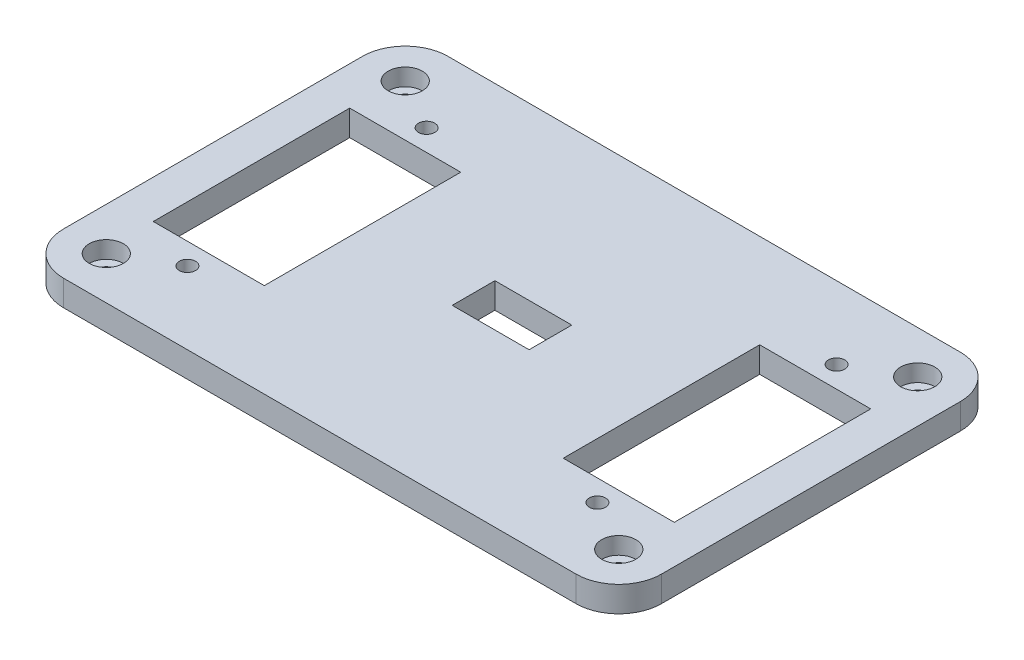
from build123d import *

# Parameters (mm, degrees)
SKETCH_1_W          = 70
SKETCH_1_H          = 45
EXTRUDE_1_DEPTH     = 3
SKETCH_2_W          = 13
SKETCH_2_H          = 23
CUT_EXTRUDE_1_DEPTH = 10
SKETCH_3_R          = 0.95
CUT_EXTRUDE_2_DEPTH = 10
FILLET_1_R          = 5
FILLET_2_R          = 5
SKETCH_4_R          = 0.95
CUT_EXTRUDE_3_DEPTH = 10
SKETCH_5_R          = 2
CUT_EXTRUDE_4_DEPTH = 2
SKETCH_6_W          = 9
SKETCH_6_H          = 5
CUT_EXTRUDE_5_DEPTH = 14


with BuildPart() as part:
    # 草图1 → 凸台-拉伸1 (new body)
    with BuildSketch(Plane(origin=(0, 0, 0), x_dir=(1, 0, 0), z_dir=(0, 1, 0))):
        Rectangle(SKETCH_1_W, SKETCH_1_H)
    extrude(amount=EXTRUDE_1_DEPTH)

    # 草图2 → 切除-拉伸1 (cut)
    with BuildSketch(Plane(origin=(0, 3, 0), x_dir=(1, 0, 0), z_dir=(0, 1, 0))):
        with Locations((24, 0)):
            Rectangle(SKETCH_2_W, SKETCH_2_H)
        with Locations((-24, 0)):
            Rectangle(SKETCH_2_W, SKETCH_2_H)
    extrude(amount=-CUT_EXTRUDE_1_DEPTH, mode=Mode.SUBTRACT)

    # 草图3 → 切除-拉伸2 (cut)
    with BuildSketch(Plane(origin=(0, 3, 0), x_dir=(1, 0, 0), z_dir=(0, 1, 0))):
        with Locations((-24, 14)):
            Circle(SKETCH_3_R)
        with Locations((-24, -14)):
            Circle(SKETCH_3_R)
        with Locations((24, 14)):
            Circle(SKETCH_3_R)
        with Locations((24, -14)):
            Circle(SKETCH_3_R)
    extrude(amount=-CUT_EXTRUDE_2_DEPTH, mode=Mode.SUBTRACT)

    # 圆角1
    fillet_1_edges = [part.edges().sort_by_distance(p)[0] for p in [
        (35, 1.5, -22.5),
    ]]
    fillet(fillet_1_edges, radius=FILLET_1_R)

    # 圆角2
    fillet_2_edges = [part.edges().sort_by_distance(p)[0] for p in [
        (35, 1.5, 22.5),
        (-35, 1.5, 22.5),
        (-35, 1.5, -22.5),
    ]]
    fillet(fillet_2_edges, radius=FILLET_2_R)

    # 草图4 → 切除-拉伸3 (cut)
    with BuildSketch(Plane(origin=(0, 3, 0), x_dir=(1, 0, 0), z_dir=(0, 1, 0))):
        with Locations((-30, 17.5)):
            Circle(SKETCH_4_R)
        with Locations((30, 17.5)):
            Circle(SKETCH_4_R)
        with Locations((-30, -17.5)):
            Circle(SKETCH_4_R)
        with Locations((30, -17.5)):
            Circle(SKETCH_4_R)
    extrude(amount=-CUT_EXTRUDE_3_DEPTH, mode=Mode.SUBTRACT)

    # 草图5 → 切除-拉伸4 (cut)
    with BuildSketch(Plane(origin=(0, 3, 0), x_dir=(1, 0, 0), z_dir=(0, 1, 0))):
        with Locations((-30, 17.5)):
            Circle(SKETCH_5_R)
        with Locations((30, 17.5)):
            Circle(SKETCH_5_R)
        with Locations((-30, -17.5)):
            Circle(SKETCH_5_R)
        with Locations((30, -17.5)):
            Circle(SKETCH_5_R)
    extrude(amount=-CUT_EXTRUDE_4_DEPTH, mode=Mode.SUBTRACT)

    # 草图6 → 切除-拉伸5 (cut)
    with BuildSketch(Plane(origin=(0, 3, 0), x_dir=(1, 0, 0), z_dir=(0, 1, 0))):
        Rectangle(SKETCH_6_W, SKETCH_6_H)
    extrude(amount=-CUT_EXTRUDE_5_DEPTH, mode=Mode.SUBTRACT)


solid = part.part
